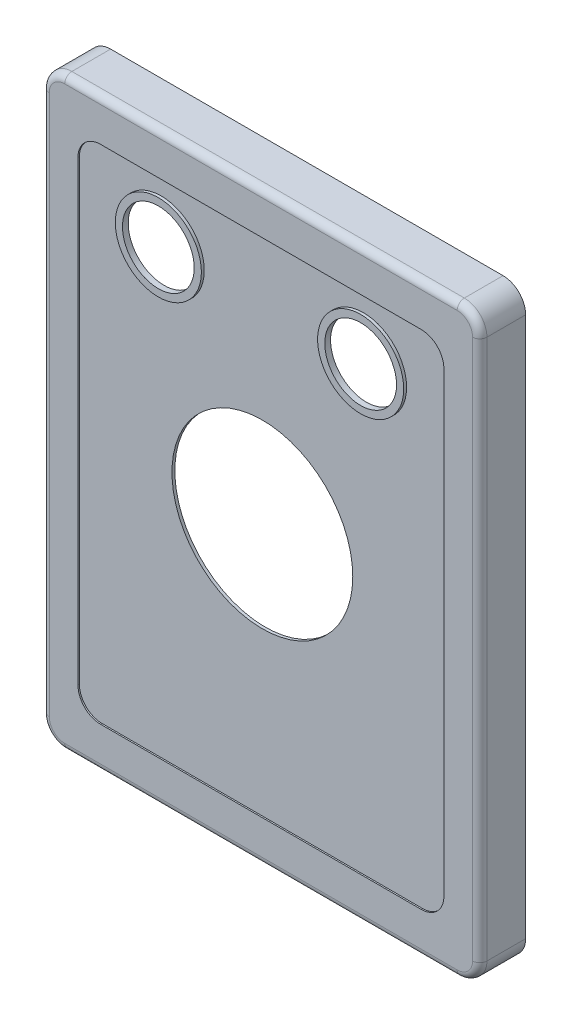
from build123d import *

# Parameters (mm, degrees)
BOSS_EXTRUDE1_DEPTH = 8.128
CUT_EXTRUDE1_DEPTH  = 0.254
FILLET3_R           = 1.27
SHELL2_T            = -0.508
SKETCH4_R           = 16.002
SKETCH4_R_2         = 6.35
CUT_EXTRUDE3_DEPTH  = 8.874
SKETCH6_R           = 7.62
SKETCH6_R_2         = 6.35
BOSS_EXTRUDE5_DEPTH = 0.508


with BuildPart() as part:
    # Sketch1 → Boss-Extrude1 (new body)
    with BuildSketch(Plane.XY):
        with BuildLine():
            Line((34.735008, -51.816), (-34.735008, -51.816))
            ThreePointArc((-34.735008, -51.816), (-37.563429468, -50.644429468), (-38.735, -47.816008))
            Line((-38.735, -47.816008), (-38.735, 47.816008))
            ThreePointArc((-38.735, 47.816008), (-37.563429468, 50.644429468), (-34.735008, 51.816))
            Line((-34.735008, 51.816), (34.735008, 51.816))
            ThreePointArc((34.735008, 51.816), (37.563429468, 50.644429468), (38.735, 47.816008))
            Line((38.735, 47.816008), (38.735, -47.816008))
            ThreePointArc((38.735, -47.816008), (37.563429468, -50.644429468), (34.735008, -51.816))
        make_face()
    extrude(amount=-BOSS_EXTRUDE1_DEPTH)

    # Sketch3 → Cut-Extrude1 (cut)
    with BuildSketch(Plane.XY):
        with BuildLine():
            Line((-28.385008, -44.45), (28.385008, -44.45))
            ThreePointArc((28.385008, -44.45), (31.213429468, -43.278429468), (32.385, -40.450008))
            Line((32.385, -40.450008), (32.385, 40.450008))
            ThreePointArc((32.385, 40.450008), (31.213429468, 43.278429468), (28.385008, 44.45))
            Line((28.385008, 44.45), (-28.385008, 44.45))
            ThreePointArc((-28.385008, 44.45), (-31.213429468, 43.278429468), (-32.385, 40.450008))
            Line((-32.385, 40.450008), (-32.385, -40.450008))
            ThreePointArc((-32.385, -40.450008), (-31.213429468, -43.278429468), (-28.385008, -44.45))
        make_face()
    extrude(amount=-CUT_EXTRUDE1_DEPTH, mode=Mode.SUBTRACT)

    # Fillet3
    fillet3_edges = [part.edges().sort_by_distance(p)[0] for p in [
        (38.735, 0, 0),
        (37.563429468, -50.644429468, 0),
        (0, -51.816, 0),
        (-37.563429468, -50.644429468, 0),
        (-38.735, 0, 0),
        (-37.563429468, 50.644429468, 0),
        (0, 51.816, 0),
        (37.563429468, 50.644429468, 0),
    ]]
    fillet(fillet3_edges, radius=FILLET3_R)

    # Shell2
    shell2_openings = [part.faces().sort_by_distance(p)[0] for p in [
        (0, 0, -8.128),
    ]]
    offset(amount=SHELL2_T, openings=shell2_openings, kind=Kind.INTERSECTION)

    # Sketch4 → Cut-Extrude3 (cut, through all)
    with BuildSketch(Plane.XY.offset(-0.254)):
        with Locations((0, 0.254)):
            Circle(SKETCH4_R)
        with Locations((17.907, 34.036)):
            Circle(SKETCH4_R_2)
        with Locations((-17.907, 34.036)):
            Circle(SKETCH4_R_2)
    extrude(amount=-CUT_EXTRUDE3_DEPTH, mode=Mode.SUBTRACT)

    # Sketch6 → Boss-Extrude5 (add)
    with BuildSketch(Plane.XY.offset(-0.254)):
        with Locations((-17.907, 34.036)):
            Circle(SKETCH6_R)
        with Locations((-17.907, 34.036)):
            Circle(SKETCH6_R_2, mode=Mode.SUBTRACT)
        with Locations((17.907, 34.036)):
            Circle(SKETCH6_R)
        with Locations((17.907, 34.036)):
            Circle(SKETCH6_R_2, mode=Mode.SUBTRACT)
    extrude(amount=BOSS_EXTRUDE5_DEPTH)


solid = part.part
